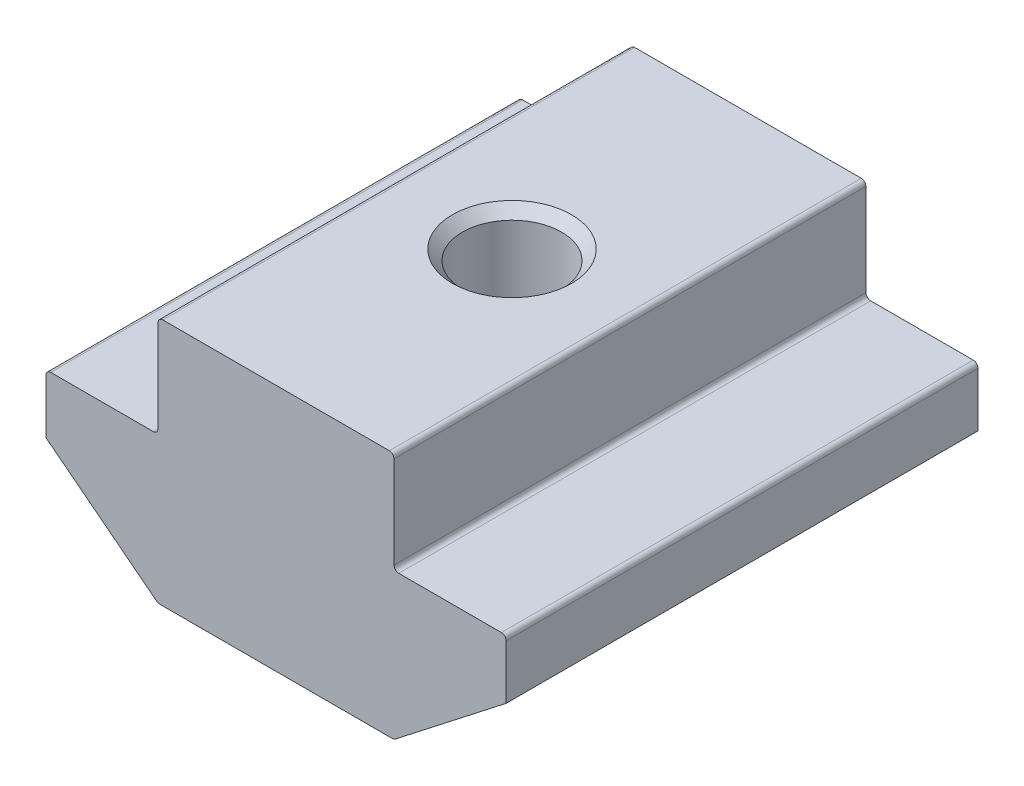
from build123d import *

# Parameters (mm, degrees)
EXTRUDE_1_DEPTH = 10
FILLET_1_R      = 0.2


with BuildPart() as part:
    # Эскиз1 → Бобышка-Вытянуть1 (new body, symmetric)
    with BuildSketch(Plane.XY):
        Polygon((5, 0), (-5, 0), (-5, -4.3), (-9.75, -4.3), (-9.75, -6.8), (-5, -10.5), (5, -10.5), (9.75, -6.8), (9.75, -4.3), (5, -4.3), align=None)
    extrude(amount=EXTRUDE_1_DEPTH, both=True)

    # Эскиз4 → Отверстие обработанное метчиком M54 (revolve, cut)
    with BuildSketch(Plane(origin=(0, 0, 0), x_dir=(0, 0, 1), z_dir=(1, 0, 0))):
        Polygon((0, 0), (0, 10.5), (2.525, 10.5), (2.1, 10.075), (2.1, 0.425), (2.525, 0), align=None)
    revolve(axis=Axis((0, 6.35, 0), (0, -1, 0)), mode=Mode.SUBTRACT)

    # Скругление1
    fillet_1_edges = [part.edges().sort_by_distance(p)[0] for p in [
        (-5, 0, 0),
        (5, 0, 0),
        (5, -4.3, 0),
        (9.75, -4.3, 0),
        (5, -10.5, 0),
        (-5, -10.5, 0),
        (-9.75, -4.3, 0),
        (-5, -4.3, 0),
    ]]
    fillet(fillet_1_edges, radius=FILLET_1_R)


solid = part.part
